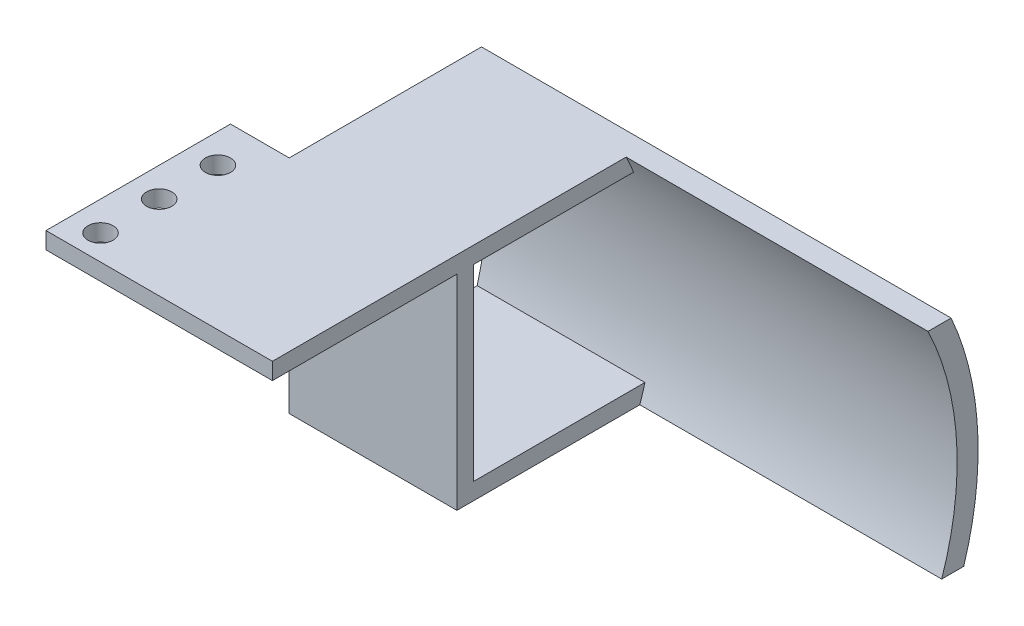
from build123d import *

# Parameters (mm, degrees)
SKETCH3_W           = 27
SKETCH3_H           = 22
SKETCH3_R           = 1.5
BOSS_EXTRUDE5_DEPTH = 2
BOSS_EXTRUDE6_DEPTH = 20
BOSS_EXTRUDE7_DEPTH = 56


with BuildPart() as part:
    # Sketch3 → Boss-Extrude5 (new body)
    with BuildSketch(Plane(origin=(0, 13.2, 0), x_dir=(1, 0, 0), z_dir=(0, 1, 0))):
        with Locations((34.5, 60.85)):
            Rectangle(SKETCH3_W, SKETCH3_H)
        with Locations((24.5, 59.85)):
            Circle(SKETCH3_R, mode=Mode.SUBTRACT)
        with Locations((24.5, 66.85)):
            Circle(SKETCH3_R, mode=Mode.SUBTRACT)
        with Locations((24.5, 52.85)):
            Circle(SKETCH3_R, mode=Mode.SUBTRACT)
    extrude(amount=BOSS_EXTRUDE5_DEPTH)

    # Sketch4 → Boss-Extrude6 (add)
    with BuildSketch(Plane.ZY.offset(-28)):
        with BuildLine():
            Line((-71.85, -11.2), (-71.85, 15.2))
            Line((-71.85, 15.2), (-92.027131173, 15.2))
            ThreePointArc((-92.027131173, 15.2), (-92.486915012, 14.206944358), (-92.915428425, 13.2))
            Line((-92.915428425, 13.2), (-73.85, 13.2))
            Line((-73.85, 13.2), (-73.85, -9.2))
            Line((-73.85, -9.2), (-94.269216751, -9.2))
            ThreePointArc((-94.269216751, -9.2), (-93.979353281, -10.204553096), (-93.659613991, -11.2))
            Line((-93.659613991, -11.2), (-71.85, -11.2))
        make_face()
    extrude(amount=-BOSS_EXTRUDE6_DEPTH)

    # Sketch4_3 → Boss-Extrude7 (add)
    with BuildSketch(Plane.ZY.offset(-28)):
        with BuildLine():
            ThreePointArc((-92.915428425, 13.2), (-92.486915012, 14.206944358), (-92.027131173, 15.2))
            Line((-92.027131173, 15.2), (-94.78133603, 15.2))
            ThreePointArc((-94.78133603, 15.2), (-97.939046263, 2.137244706), (-96.288405944, -11.2))
            Line((-96.288405944, -11.2), (-93.659613991, -11.2))
            ThreePointArc((-93.659613991, -11.2), (-93.979353281, -10.204553096), (-94.269216751, -9.2))
            ThreePointArc((-94.269216751, -9.2), (-95.436253581, 2.111441618), (-92.915428425, 13.2))
        make_face()
    extrude(amount=-BOSS_EXTRUDE7_DEPTH)


solid = part.part
